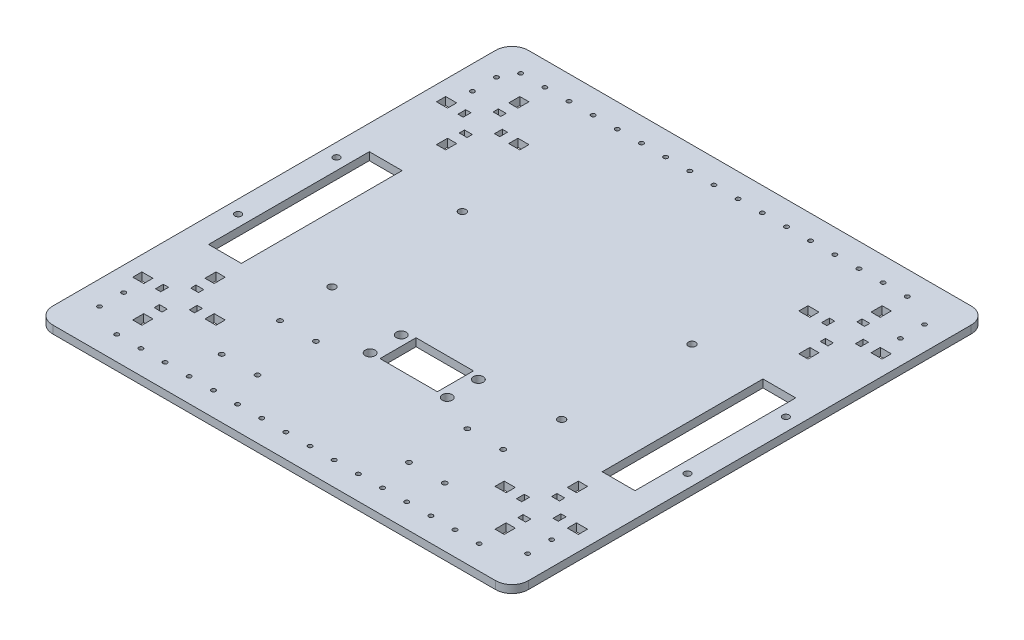
from build123d import *

# Parameters (mm, degrees)
SKETCH1_W                 = 290
SKETCH1_H                 = 290
BASE_PLATE_DEPTH          = 4.7625
CASTER_HOLES_D            = 2.6
FILLET1_R                 = 10
SKETCH5_R                 = 3
SKETCH5_W                 = 35
SKETCH5_H                 = 22
REFLECT_HOLES_DEPTH       = 4.7625
SKETCH6_R                 = 2
SKETCH6_R_2               = 2.25
BEARING_SLOTS_DEPTH       = 4.7625
SKETCH7_W                 = 20
SKETCH7_H                 = 98
WHEEL_SLOTS_DEPTH         = 4.7625
SKETCH15_W                = 5.588
SKETCH15_H                = 6.731
SKETCH15_W_2              = 6.731
SKETCH15_H_2              = 5.588
SKETCH15_W_3              = 4.7625
SKETCH15_H_3              = 3.2
SKETCH15_W_4              = 3.2
SKETCH15_H_4              = 4.7625
CUT_EXTRUDE2_DEPTH        = 4.7625
MIRROR3_COPY_1_SKETCH_W   = 5.588
MIRROR3_COPY_1_SKETCH_H   = 6.731
MIRROR3_COPY_1_SKETCH_W_2 = 6.731
MIRROR3_COPY_1_SKETCH_H_2 = 5.588
MIRROR3_COPY_1_SKETCH_W_3 = 4.7625
MIRROR3_COPY_1_SKETCH_H_3 = 3.2
MIRROR3_COPY_1_SKETCH_W_4 = 3.2
MIRROR3_COPY_1_SKETCH_H_4 = 4.7625
MIRROR3_COPY_1_DEPTH      = 4.7625
SKETCH16_R                = 1.5
CUT_EXTRUDE3_DEPTH        = 4.7625
SKETCH17_R                = 1.3
CUT_EXTRUDE4_DEPTH        = 4.7625


with BuildPart() as part:
    # Sketch1 → Base Plate (new body)
    with BuildSketch(Plane(origin=(0, 0, 0), x_dir=(1, 0, 0), z_dir=(0, 1, 0))):
        Rectangle(SKETCH1_W, SKETCH1_H)
    extrude(amount=BASE_PLATE_DEPTH)

    # Caster Holes (through all)
    with Locations(Plane(origin=(0, 4.7625, 0), x_dir=(1, 0, 0), z_dir=(0, 1, 0))):
        with Locations((-125.222, 130.5), (-7.366, 130.5), (-22.098, 130.5), (-36.83, 130.5), (-51.562, 130.5), (-66.294, 130.5), (-81.026, 130.5), (-95.758, 130.5), (-110.49, 130.5), (110.49, 130.5), (95.758, 130.5), (81.026, 130.5), (66.294, 130.5), (51.562, 130.5), (36.83, 130.5), (22.098, 130.5), (7.366, 130.5), (7.366, -130.5), (22.098, -130.5), (36.83, -130.5), (51.562, -130.5), (66.294, -130.5), (81.026, -130.5), (95.758, -130.5), (110.49, -130.5), (-110.49, -130.5), (-95.758, -130.5), (-81.026, -130.5), (-66.294, -130.5), (-51.562, -130.5), (-36.83, -130.5), (-22.098, -130.5), (-7.366, -130.5)):
            Hole(CASTER_HOLES_D / 2)

    # Fillet1
    fillet1_edges = [part.edges().sort_by_distance(p)[0] for p in [
        (-145, 2.38125, -145),
        (145, 2.38125, -145),
        (145, 2.38125, 145),
        (-145, 2.38125, 145),
    ]]
    fillet(fillet1_edges, radius=FILLET1_R)

    # Sketch5 → Reflect Holes (cut)
    with BuildSketch(Plane(origin=(0, 4.7625, 0), x_dir=(1, 0, 0), z_dir=(0, 1, 0))):
        with Locations((-23.5, -44)):
            Circle(SKETCH5_R)
        with Locations((-23.5, -63)):
            Circle(SKETCH5_R)
        with Locations((23.5, -63)):
            Circle(SKETCH5_R)
        with Locations((23.5, -44)):
            Circle(SKETCH5_R)
        with Locations((0, -52)):
            Rectangle(SKETCH5_W, SKETCH5_H)
    extrude(amount=-REFLECT_HOLES_DEPTH, mode=Mode.SUBTRACT)

    # Sketch6 → bearing slots (cut)
    with BuildSketch(Plane(origin=(0, 4.7625, 0), x_dir=(1, 0, 0), z_dir=(0, 1, 0))):
        with Locations((-137, 30)):
            Circle(SKETCH6_R)
        with Locations((-137, -30)):
            Circle(SKETCH6_R)
        with Locations((-70, 39.748)):
            Circle(SKETCH6_R_2)
        with Locations((-70, -39.748)):
            Circle(SKETCH6_R_2)
        with Locations((70, -39.748)):
            Circle(SKETCH6_R_2)
        with Locations((70, 39.748)):
            Circle(SKETCH6_R_2)
        with Locations((137, -30)):
            Circle(SKETCH6_R)
        with Locations((137, 30)):
            Circle(SKETCH6_R)
    extrude(amount=-BEARING_SLOTS_DEPTH, mode=Mode.SUBTRACT)

    # Sketch7 → wheel slots (cut)
    with BuildSketch(Plane(origin=(0, 4.7625, 0), x_dir=(1, 0, 0), z_dir=(0, 1, 0))):
        with Locations((-120, -6)):
            Rectangle(SKETCH7_W, SKETCH7_H)
    wheel_slots = extrude(amount=-WHEEL_SLOTS_DEPTH, mode=Mode.SUBTRACT)

    # Mirror1: wheel slots across plane
    add(wheel_slots.mirror(Plane(origin=(0, 0, 0), x_dir=(0, 0, 1), z_dir=(1, 0, 0))), mode=Mode.SUBTRACT)

    # Sketch15 → Cut-Extrude2 (cut)
    with BuildSketch(Plane(origin=(0, 4.7625, 0), x_dir=(1, 0, 0), z_dir=(0, 1, 0))):
        with Locations((-110.456, 114.6345)):
            Rectangle(SKETCH15_W, SKETCH15_H)
        with Locations((-88.4215, 92.6)):
            Rectangle(SKETCH15_W_2, SKETCH15_H_2)
        with Locations((-110.456, 70.5655)):
            Rectangle(SKETCH15_W, SKETCH15_H)
        with Locations((-132.4905, 92.6)):
            Rectangle(SKETCH15_W_2, SKETCH15_H_2)
        with Locations((-110.86875, 103.325)):
            Rectangle(SKETCH15_W_3, SKETCH15_H_3)
        with Locations((-121.181, 92.18725)):
            Rectangle(SKETCH15_W_4, SKETCH15_H_4)
        with Locations((-99.731, 93.01275)):
            Rectangle(SKETCH15_W_4, SKETCH15_H_4)
        with Locations((-110.04325, 81.875)):
            Rectangle(SKETCH15_W_3, SKETCH15_H_3)
    cut_extrude2 = extrude(amount=-CUT_EXTRUDE2_DEPTH, mode=Mode.SUBTRACT)

    # Mirror2: Cut-Extrude2 across plane
    add(cut_extrude2.mirror(Plane(origin=(0, 0, 0), x_dir=(0, 0, 1), z_dir=(1, 0, 0))), mode=Mode.SUBTRACT)

    # Mirror3: Cut-Extrude2 across plane
    add(cut_extrude2.mirror(Plane.XY), mode=Mode.SUBTRACT)

    # Mirror3 copy 1 sketch → Mirror3 copy 1 (cut)
    with BuildSketch(Plane(origin=(0, 4.7625, 0), x_dir=(-1, 0, 0), z_dir=(0, 1, 0))):
        with Locations((-110.456, 114.6345)):
            Rectangle(MIRROR3_COPY_1_SKETCH_W, MIRROR3_COPY_1_SKETCH_H)
        with Locations((-88.4215, 92.6)):
            Rectangle(MIRROR3_COPY_1_SKETCH_W_2, MIRROR3_COPY_1_SKETCH_H_2)
        with Locations((-110.456, 70.5655)):
            Rectangle(MIRROR3_COPY_1_SKETCH_W, MIRROR3_COPY_1_SKETCH_H)
        with Locations((-132.4905, 92.6)):
            Rectangle(MIRROR3_COPY_1_SKETCH_W_2, MIRROR3_COPY_1_SKETCH_H_2)
        with Locations((-110.86875, 103.325)):
            Rectangle(MIRROR3_COPY_1_SKETCH_W_3, MIRROR3_COPY_1_SKETCH_H_3)
        with Locations((-121.181, 92.18725)):
            Rectangle(MIRROR3_COPY_1_SKETCH_W_4, MIRROR3_COPY_1_SKETCH_H_4)
        with Locations((-99.731, 93.01275)):
            Rectangle(MIRROR3_COPY_1_SKETCH_W_4, MIRROR3_COPY_1_SKETCH_H_4)
        with Locations((-110.04325, 81.875)):
            Rectangle(MIRROR3_COPY_1_SKETCH_W_3, MIRROR3_COPY_1_SKETCH_H_3)
    extrude(amount=-MIRROR3_COPY_1_DEPTH, mode=Mode.SUBTRACT)

    # Sketch16 → Cut-Extrude3 (cut)
    with BuildSketch(Plane(origin=(0, 4.7625, 0), x_dir=(1, 0, 0), z_dir=(0, 1, 0))):
        with Locations((-68, -73.437)):
            Circle(SKETCH16_R)
        with Locations((-46.16, -73.437)):
            Circle(SKETCH16_R)
        with Locations((-46.16, -109)):
            Circle(SKETCH16_R)
        with Locations((-68, -109)):
            Circle(SKETCH16_R)
        with Locations((46.16, -73.437)):
            Circle(SKETCH16_R)
        with Locations((46.16, -109)):
            Circle(SKETCH16_R)
        with Locations((68, -109)):
            Circle(SKETCH16_R)
        with Locations((68, -73.437)):
            Circle(SKETCH16_R)
    extrude(amount=-CUT_EXTRUDE3_DEPTH, mode=Mode.SUBTRACT)

    # Sketch17 → Cut-Extrude4 (cut)
    with BuildSketch(Plane(origin=(0, 4.7625, 0), x_dir=(1, 0, 0), z_dir=(0, 1, 0))):
        with Locations((-130.5, 121)):
            Circle(SKETCH17_R)
        with Locations((-130.5, 106.3)):
            Circle(SKETCH17_R)
        with Locations((-130.5, -106.3)):
            Circle(SKETCH17_R)
        with Locations((-130.5, -121)):
            Circle(SKETCH17_R)
        with Locations((130.5, -121)):
            Circle(SKETCH17_R)
        with Locations((130.5, -106.3)):
            Circle(SKETCH17_R)
        with Locations((130.5, 106.3)):
            Circle(SKETCH17_R)
        with Locations((130.5, 121)):
            Circle(SKETCH17_R)
    extrude(amount=-CUT_EXTRUDE4_DEPTH, mode=Mode.SUBTRACT)


solid = part.part
